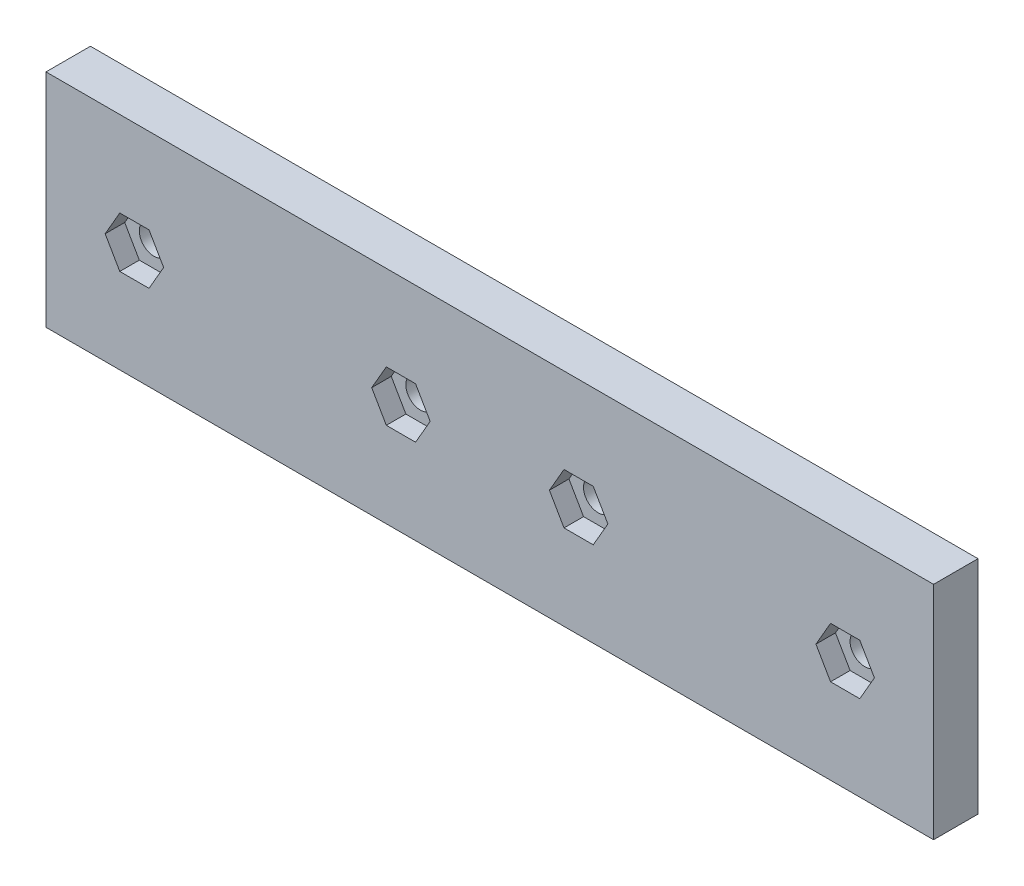
from build123d import *

# Parameters (mm, degrees)
SKETCH1_W           = 99.9
SKETCH1_H           = 24.9
SKETCH1_R           = 1.65
BOSS_EXTRUDE1_DEPTH = 5
CUT_EXTRUDE1_DEPTH  = 2.2


with BuildPart() as part:
    # Sketch1 → Boss-Extrude1 (new body)
    with BuildSketch(Plane.XY.offset(-70.679368873)):
        with Locations((22.473815584, 78.921604181)):
            Rectangle(SKETCH1_W, SKETCH1_H)
        with Locations((-17.526184416, 78.921604181)):
            Circle(SKETCH1_R, mode=Mode.SUBTRACT)
        with Locations((12.473815584, 78.921604181)):
            Circle(SKETCH1_R, mode=Mode.SUBTRACT)
        with Locations((32.473815584, 78.921604181)):
            Circle(SKETCH1_R, mode=Mode.SUBTRACT)
        with Locations((62.473815584, 78.921604181)):
            Circle(SKETCH1_R, mode=Mode.SUBTRACT)
    extrude(amount=BOSS_EXTRUDE1_DEPTH)

    # Sketch2 → Cut-Extrude1 (cut)
    with BuildSketch(Plane.XY.offset(-65.679368873)):
        Polygon((-15.880736149, 76.071604181), (-14.235287881, 78.921604181), (-15.880736149, 81.771604181), (-19.171632683, 81.771604181), (-20.81708095, 78.921604181), (-19.171632683, 76.071604181), align=None)
        Polygon((14.119263851, 76.071604181), (15.764712119, 78.921604181), (14.119263851, 81.771604181), (10.828367317, 81.771604181), (9.18291905, 78.921604181), (10.828367317, 76.071604181), align=None)
        Polygon((34.119263851, 76.071604181), (35.764712119, 78.921604181), (34.119263851, 81.771604181), (30.828367317, 81.771604181), (29.18291905, 78.921604181), (30.828367317, 76.071604181), align=None)
        Polygon((64.119263851, 76.071604181), (65.764712119, 78.921604181), (64.119263851, 81.771604181), (60.828367317, 81.771604181), (59.18291905, 78.921604181), (60.828367317, 76.071604181), align=None)
    extrude(amount=-CUT_EXTRUDE1_DEPTH, mode=Mode.SUBTRACT)


solid = part.part
